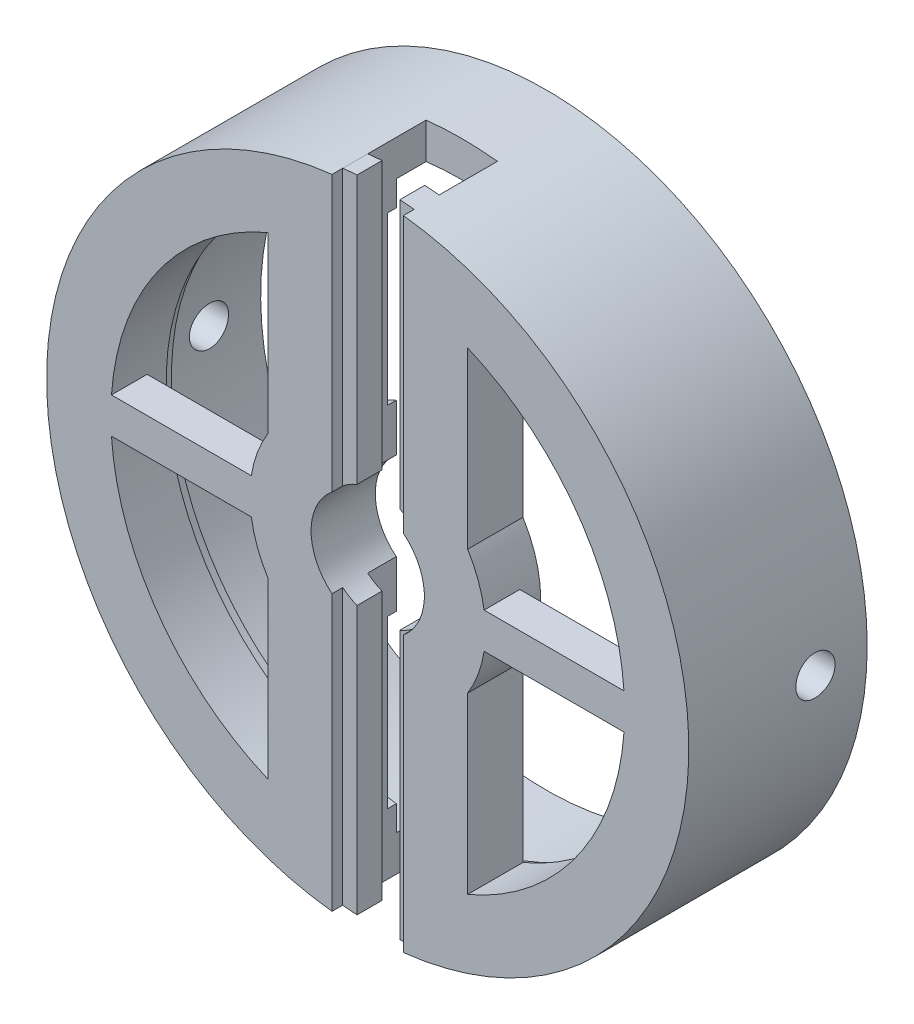
from build123d import *

# Parameters (mm, degrees)
CUT_EXTRUDE1_DEPTH       = 91
CUT_EXTRUDE13_START      = 79.372539
SKETCH35_W               = 20
SKETCH35_H               = 8.35
CUT_EXTRUDE13_DEPTH      = 10.627461
CIRPATTERN1_COUNT        = 2
CUT_EXTRUDE14_DEPTH      = 64
SKETCH38_W               = 301.896550135
SKETCH38_H               = 232.512752758
CUT_EXTRUDE15_DEPTH      = 13
SKETCH39_W               = 54.010562882
SKETCH39_H               = 10
SKETCH39_W_2             = 56.106077308
BOSS_EXTRUDE1_DEPTH      = 10
SKETCH17_R               = 5.5
CUT_EXTRUDE18_DEPTH      = 181
CUT_EXTRUDE18_DEPTH_BACK = 1
SKETCH42_R               = 15.875
CUT_EXTRUDE19_DEPTH      = 40


with BuildPart() as part:
    # Sketch3 → Revolve2 (revolve)
    with BuildSketch(Plane(origin=(0, 0, 0), x_dir=(0, 0, -1), z_dir=(1, 0, 0))):
        Polygon((-45, 80), (0, 80), (0, 90), (-63, 90), (-63, 15), (-45, 15), (-45, 27.5), (-47.5, 27.5), (-47.5, 73), (-45, 73), align=None)
    revolve(axis=Axis((0, 0, 0), (0, 0, 1)))

    # Sketch4 → Cut-Extrude1 (cut, through all)
    with BuildSketch(Plane(origin=(0, 0, 0), x_dir=(1, 0, 0), z_dir=(0, 1, 0))):
        Polygon((10, -53), (10, -45), (-10, -45), (-10, -53), (-6, -53), (-6, -60), (-10, -60), (-10, -63), (10, -63), (10, -60), (6, -60), (6, -53), align=None)
    cut_extrude1 = extrude(amount=CUT_EXTRUDE1_DEPTH, mode=Mode.SUBTRACT)

    # Sketch35 → Cut-Extrude13 (cut)
    with BuildSketch(Plane(origin=(0, 0, 0), x_dir=(1, 0, 0), z_dir=(0, 1, 0)).offset(CUT_EXTRUDE13_START)):
        with Locations((0, -40.825)):
            Rectangle(SKETCH35_W, SKETCH35_H)
    cut_extrude13 = extrude(amount=CUT_EXTRUDE13_DEPTH, mode=Mode.SUBTRACT)

    # CirPattern1: Cut-Extrude1, Cut-Extrude13 ×2 about axis
    cirpattern1_axis = Axis((0, 0, 0), (0, 0, 1))
    for i in range(1, CIRPATTERN1_COUNT):
        add(cut_extrude1.rotate(cirpattern1_axis, i * 360 / CIRPATTERN1_COUNT), mode=Mode.SUBTRACT)
        add(cut_extrude13.rotate(cirpattern1_axis, i * 360 / CIRPATTERN1_COUNT), mode=Mode.SUBTRACT)

    # Sketch37 → Cut-Extrude14 (cut, through all)
    with BuildSketch(Plane.XY.offset(63)):
        with BuildLine():
            Line((-28, -66.332495807), (-28, -17.464249197))
            ThreePointArc((-28, -17.464249197), (-33, 0), (-28, 17.464249197))
            Line((-28, 17.464249197), (-28, 66.332495807))
            ThreePointArc((-28, 66.332495807), (-72, 0), (-28, -66.332495807))
        make_face()
        with BuildLine():
            Line((28, -17.464249197), (28, -66.332495807))
            ThreePointArc((28, -66.332495807), (72, 0), (28, 66.332495807))
            Line((28, 66.332495807), (28, 17.464249197))
            ThreePointArc((28, 17.464249197), (33, 0), (28, -17.464249197))
        make_face()
    extrude(amount=-CUT_EXTRUDE14_DEPTH, mode=Mode.SUBTRACT)

    # Sketch38 → Cut-Extrude15 (cut)
    with BuildSketch(Plane(origin=(0, 0, 0), x_dir=(-1, 0, 0), z_dir=(0, 0, -1))):
        with Locations((8.285843347, -5.180042081)):
            Rectangle(SKETCH38_W, SKETCH38_H)
    extrude(amount=-CUT_EXTRUDE15_DEPTH, mode=Mode.SUBTRACT)

    # Sketch39 → Boss-Extrude1 (add)
    with BuildSketch(Plane.XY.offset(63)):
        with Locations((47.183112068, 0)):
            Rectangle(SKETCH39_W, SKETCH39_H)
        with Locations((-51.507331201, 0)):
            Rectangle(SKETCH39_W_2, SKETCH39_H)
    extrude(amount=-BOSS_EXTRUDE1_DEPTH)

    # Sketch17 → Cut-Extrude18 (cut, two sides)
    with BuildSketch(Plane(origin=(-90, 0, 0), x_dir=(0, 0, -1), z_dir=(1, 0, 0))) as cut_extrude18_sk:
        with Locations((-27.5, 0)):
            Circle(SKETCH17_R)
    extrude(amount=CUT_EXTRUDE18_DEPTH, mode=Mode.SUBTRACT)
    extrude(cut_extrude18_sk.sketch, amount=-CUT_EXTRUDE18_DEPTH_BACK, mode=Mode.SUBTRACT)

    # Sketch42 → Cut-Extrude19 (cut)
    with BuildSketch(Plane.XY.offset(63)):
        Circle(SKETCH42_R)
    extrude(amount=-CUT_EXTRUDE19_DEPTH, mode=Mode.SUBTRACT)


solid = part.part
